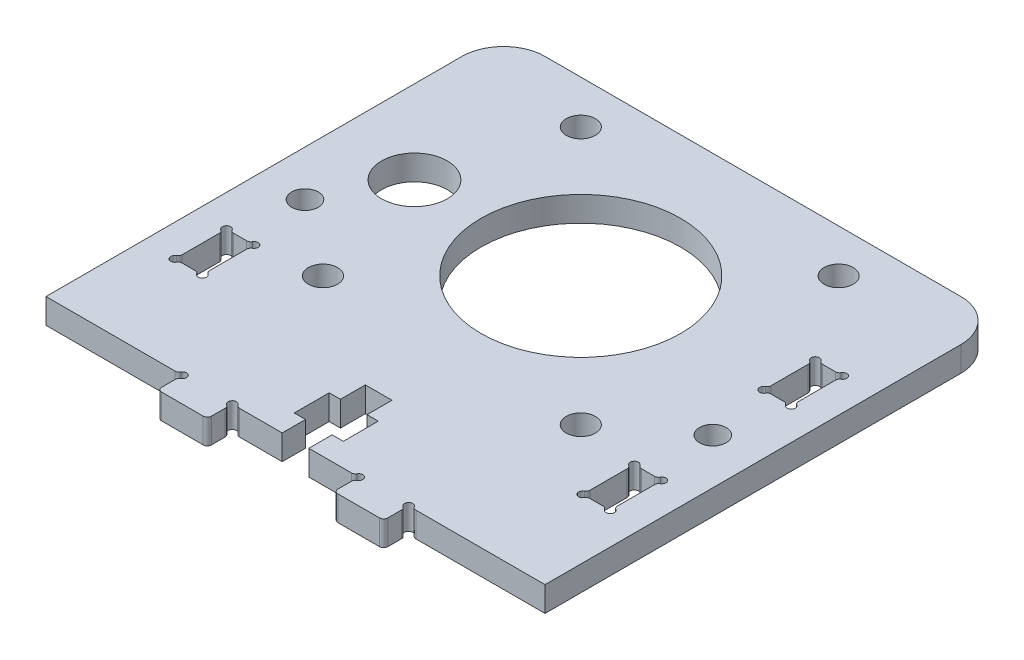
from build123d import *

# Parameters (mm, degrees)
SKETCH1_R           = 1.6
SKETCH1_R_2         = 1.75
SKETCH1_R_3         = 3.95
SKETCH1_R_4         = 12
BOSS_EXTRUDE1_DEPTH = 3


with BuildPart() as part:
    # Sketch1 → Boss-Extrude1 (new body)
    with BuildSketch(Plane(origin=(0, 0, 0), x_dir=(1, 0, 0), z_dir=(0, 1, 0))):
        with BuildLine():
            Line((312.373352996, 1022.190294437), (327.907309833, 1022.190294437))
            ThreePointArc((327.907309833, 1022.190294437), (328.157309833, 1022.257281735), (328.340322535, 1022.440294437))
            ThreePointArc((328.340322535, 1022.440294437), (329.126888323, 1022.543848684), (329.023336329, 1021.757282599))
            ThreePointArc((329.023336329, 1021.757282599), (328.840324865, 1021.574270305), (328.773337833, 1021.324271437))
            Line((328.773337833, 1021.324271437), (328.773337833, 1019.690242437))
            ThreePointArc((328.773337833, 1019.690242437), (328.919784442, 1019.336689047), (329.273337833, 1019.190242437))
            Line((329.273337833, 1019.190242437), (334.273335833, 1019.190242437))
            ThreePointArc((334.273335833, 1019.190242437), (334.626889492, 1019.336688397), (334.773336751, 1019.690241519))
            Line((334.773336751, 1019.690241519), (334.773336751, 1021.324268519))
            ThreePointArc((334.773336751, 1021.324268519), (334.706349307, 1021.57426848), (334.523336498, 1021.757281075))
            ThreePointArc((334.523336498, 1021.757281075), (334.419781792, 1022.543846802), (335.206347937, 1022.440295269))
            ThreePointArc((335.206347937, 1022.440295269), (335.389360338, 1022.257283911), (335.639359245, 1022.190297025))
            Line((335.639359245, 1022.190297025), (340.773337745, 1022.190297025))
            Line((340.773337745, 1022.190297025), (340.773337745, 1024.990297025))
            Line((340.773337745, 1024.990297025), (339.423337745, 1024.990297025))
            Line((339.423337745, 1024.990297025), (339.423337745, 1029.190297025))
            Line((339.423337745, 1029.190297025), (340.773337745, 1029.190297025))
            Line((340.773337745, 1029.190297025), (340.773337745, 1032.190297025))
            Line((340.773337745, 1032.190297025), (343.973337745, 1032.190297025))
            Line((343.973337745, 1032.190297025), (343.973337745, 1029.190297025))
            Line((343.973337745, 1029.190297025), (345.323337745, 1029.190297025))
            Line((345.323337745, 1029.190297025), (345.323337745, 1024.990292188))
            Line((345.323337745, 1024.990292188), (343.973337745, 1024.990292188))
            Line((343.973337745, 1024.990292188), (343.973337745, 1022.190292188))
            Line((343.973337745, 1022.190292188), (349.107314245, 1022.190292188))
            ThreePointArc((349.107314245, 1022.190292188), (349.357314245, 1022.257279486), (349.540326947, 1022.440292188))
            ThreePointArc((349.540326947, 1022.440292188), (350.326891976, 1022.543845827), (350.223341741, 1021.75728035))
            ThreePointArc((350.223341741, 1021.75728035), (350.040330277, 1021.574268055), (349.973343245, 1021.324269188))
            Line((349.973343245, 1021.324269188), (349.973343245, 1019.690240188))
            ThreePointArc((349.973343245, 1019.690240188), (350.119789854, 1019.336686797), (350.473343245, 1019.190240188))
            Line((350.473343245, 1019.190240188), (355.473340245, 1019.190240188))
            ThreePointArc((355.473340245, 1019.190240188), (355.826893904, 1019.336686148), (355.973341163, 1019.69023927))
            Line((355.973341163, 1019.69023927), (355.973341163, 1021.32426627))
            ThreePointArc((355.973341163, 1021.32426627), (355.906353816, 1021.574266257), (355.723341079, 1021.757278924))
            ThreePointArc((355.723341079, 1021.757278924), (355.619786681, 1022.543844692), (356.406352785, 1022.44029285))
            ThreePointArc((356.406352785, 1022.44029285), (356.589365548, 1022.257281171), (356.839364996, 1022.190294437))
            Line((356.839364996, 1022.190294437), (372.373340046, 1022.190294437))
            Line((372.373340046, 1022.190294437), (372.373340046, 1072.190301225))
            ThreePointArc((372.373340046, 1072.190301225), (370.908875012, 1075.72583207), (367.373345046, 1077.190299225))
            Line((367.373345046, 1077.190299225), (317.373348046, 1077.190299225))
            ThreePointArc((317.373348046, 1077.190299225), (313.837816014, 1075.725834155), (312.373352996, 1072.190301275))
            Line((312.373352996, 1072.190301275), (312.373352996, 1022.190294437))
        make_face()
        with Locations((366.893344996, 1047.842461747)):
            Circle(SKETCH1_R, mode=Mode.SUBTRACT)
        with Locations((357.873345496, 1071.990299275)):
            Circle(SKETCH1_R_2, mode=Mode.SUBTRACT)
        with Locations((357.873345496, 1040.990299275)):
            Circle(SKETCH1_R_2, mode=Mode.SUBTRACT)
        with Locations((322.373345996, 1056.490299275)):
            Circle(SKETCH1_R_3, mode=Mode.SUBTRACT)
        with Locations((342.373345496, 1056.490299275)):
            Circle(SKETCH1_R_4, mode=Mode.SUBTRACT)
        with Locations((326.873345496, 1071.990299275)):
            Circle(SKETCH1_R_2, mode=Mode.SUBTRACT)
        with Locations((326.873345496, 1040.990299275)):
            Circle(SKETCH1_R_2, mode=Mode.SUBTRACT)
        with Locations((317.853347996, 1047.84952041)):
            Circle(SKETCH1_R, mode=Mode.SUBTRACT)
        with BuildLine():
            Line((365.243389653, 1060.95296097), (365.243389653, 1056.48501097))
            ThreePointArc((365.243389653, 1056.48501097), (365.176400533, 1056.235010504), (364.993385671, 1056.051998658))
            ThreePointArc((364.993385671, 1056.051998658), (364.889836092, 1055.26543287), (365.676401176, 1055.368987799))
            ThreePointArc((365.676401176, 1055.368987799), (365.859413353, 1055.55200075), (366.109412996, 1055.618988627))
            Line((366.109412996, 1055.618988627), (367.677282996, 1055.618988627))
            ThreePointArc((367.677282996, 1055.618988627), (367.927282247, 1055.552001761), (368.110294834, 1055.368990124))
            ThreePointArc((368.110294834, 1055.368990124), (368.896860423, 1055.26543905), (368.793306996, 1056.052004329))
            ThreePointArc((368.793306996, 1056.052004329), (368.610294145, 1056.235017289), (368.543306996, 1056.485017627))
            Line((368.543306996, 1056.485017627), (368.543306996, 1060.952967627))
            ThreePointArc((368.543306996, 1060.952967627), (368.610293862, 1061.202966879), (368.793305499, 1061.385979465))
            ThreePointArc((368.793305499, 1061.385979465), (368.89685718, 1062.172545813), (368.110291294, 1062.068990627))
            ThreePointArc((368.110291294, 1062.068990627), (367.927278767, 1061.885978026), (367.677278996, 1061.818990627))
            Line((367.677278996, 1061.818990627), (366.109410996, 1061.818990627))
            ThreePointArc((366.109410996, 1061.818990627), (365.859411616, 1061.885977015), (365.676398679, 1062.068988302))
            ThreePointArc((365.676398679, 1062.068988302), (364.889832133, 1062.172538478), (364.993388824, 1061.38597279))
            ThreePointArc((364.993388824, 1061.38597279), (365.176401775, 1061.202960613), (365.243389653, 1060.95296097))
        make_face(mode=Mode.SUBTRACT)
        with BuildLine():
            Line((316.203388653, 1039.193570463), (316.203388653, 1034.725621463))
            ThreePointArc((316.203388653, 1034.725621463), (316.136399531, 1034.475620993), (315.953384663, 1034.292609147))
            ThreePointArc((315.953384663, 1034.292609147), (315.849835095, 1033.506043359), (316.636400176, 1033.609598291))
            ThreePointArc((316.636400176, 1033.609598291), (316.819412786, 1033.792611493), (317.069412996, 1033.85959912))
            Line((317.069412996, 1033.85959912), (318.637282996, 1033.85959912))
            ThreePointArc((318.637282996, 1033.85959912), (318.887282247, 1033.792612254), (319.070294834, 1033.609600616))
            ThreePointArc((319.070294834, 1033.609600616), (319.856860423, 1033.506049543), (319.753306996, 1034.292614822))
            ThreePointArc((319.753306996, 1034.292614822), (319.570294395, 1034.475627349), (319.503306996, 1034.72562712))
            Line((319.503306996, 1034.72562712), (319.503306996, 1039.19357712))
            ThreePointArc((319.503306996, 1039.19357712), (319.570293862, 1039.443576372), (319.753305499, 1039.626588958))
            ThreePointArc((319.753305499, 1039.626588958), (319.856856573, 1040.413154547), (319.070291294, 1040.30960112))
            ThreePointArc((319.070291294, 1040.30960112), (318.887278334, 1040.126588269), (318.637277996, 1040.05960112))
            Line((318.637277996, 1040.05960112), (317.069410996, 1040.05960112))
            ThreePointArc((317.069410996, 1040.05960112), (316.819411616, 1040.126587508), (316.636398679, 1040.309598795))
            ThreePointArc((316.636398679, 1040.309598795), (315.849832892, 1040.413148364), (315.953387824, 1039.626583283))
            ThreePointArc((315.953387824, 1039.626583283), (316.136401025, 1039.443570673), (316.203388653, 1039.193570463))
        make_face(mode=Mode.SUBTRACT)
        with BuildLine():
            Line((368.543303996, 1034.72562712), (368.543303996, 1039.19357712))
            ThreePointArc((368.543303996, 1039.19357712), (368.610290862, 1039.443576372), (368.793302499, 1039.626588958))
            ThreePointArc((368.793302499, 1039.626588958), (368.896853573, 1040.413154547), (368.110288294, 1040.30960112))
            ThreePointArc((368.110288294, 1040.30960112), (367.927275767, 1040.126588519), (367.677275996, 1040.05960112))
            Line((367.677275996, 1040.05960112), (366.109407996, 1040.05960112))
            ThreePointArc((366.109407996, 1040.05960112), (365.859408616, 1040.126587508), (365.676395679, 1040.309598795))
            ThreePointArc((365.676395679, 1040.309598795), (364.889829133, 1040.413148971), (364.993385824, 1039.626583283))
            ThreePointArc((364.993385824, 1039.626583283), (365.176399025, 1039.443570673), (365.243386653, 1039.193570463))
            Line((365.243386653, 1039.193570463), (365.243386653, 1034.725621463))
            ThreePointArc((365.243386653, 1034.725621463), (365.176397531, 1034.475620993), (364.993382663, 1034.292609147))
            ThreePointArc((364.993382663, 1034.292609147), (364.889833095, 1033.506043359), (365.676398176, 1033.609598291))
            ThreePointArc((365.676398176, 1033.609598291), (365.859410353, 1033.792611243), (366.109409996, 1033.85959912))
            Line((366.109409996, 1033.85959912), (367.677279996, 1033.85959912))
            ThreePointArc((367.677279996, 1033.85959912), (367.927279247, 1033.792612254), (368.110291834, 1033.609600616))
            ThreePointArc((368.110291834, 1033.609600616), (368.896857423, 1033.506049543), (368.793303996, 1034.292614822))
            ThreePointArc((368.793303996, 1034.292614822), (368.610291395, 1034.475627349), (368.543303996, 1034.72562712))
        make_face(mode=Mode.SUBTRACT)
    extrude(amount=BOSS_EXTRUDE1_DEPTH)


solid = part.part
